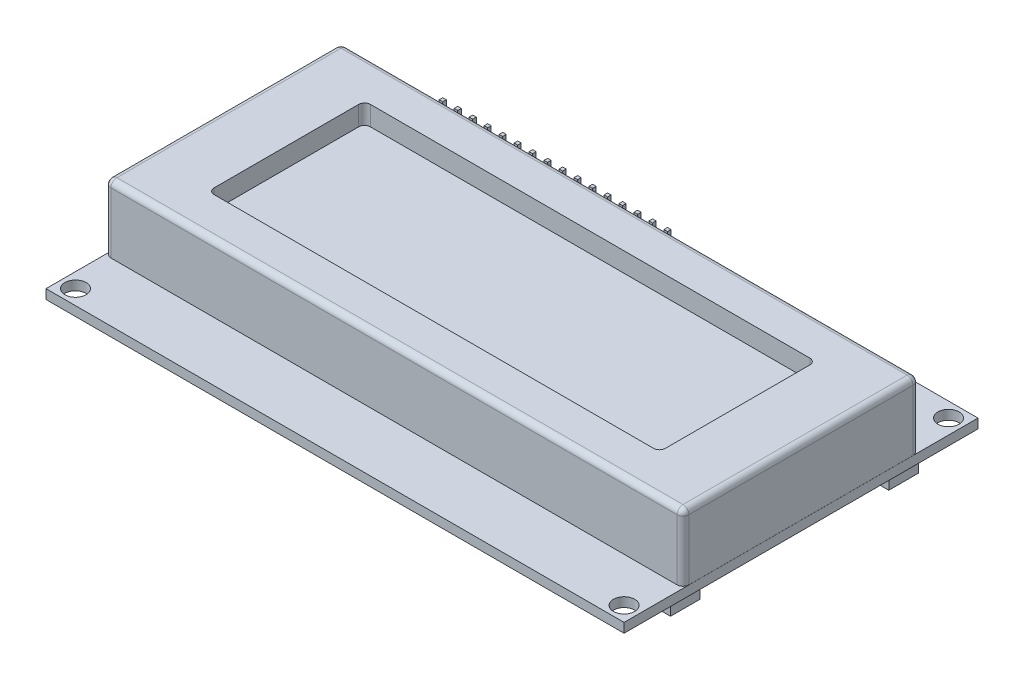
from build123d import *

# Parameters (mm, degrees)
SKETCH1_W               = 98
SKETCH1_H               = 60
BOSS_EXTRUDE1_DEPTH     = 1.6
CUT_EXTRUDE1_START      = -2.6
SKETCH2_R               = 1.8
CUT_EXTRUDE1_DEPTH      = 3.6
SKETCH5_W               = 7
SKETCH5_H               = 5
BOSS_EXTRUDE3_DEPTH     = 2.57
MIRROR2_START           = -2.6
MIRROR2_COPY_1_SKETCH_R = 1.8
MIRROR2_COPY_1_DEPTH    = 3.6
MIRROR2_COPY_2_SKETCH_W = 7
MIRROR2_COPY_2_SKETCH_H = 5
MIRROR2_COPY_2_DEPTH    = 2.57
SKETCH3_W               = 97.98
SKETCH3_H               = 40
BOSS_EXTRUDE2_DEPTH     = 11.3
SKETCH4_W               = 76.5
SKETCH4_H               = 26.5
CUT_EXTRUDE2_DEPTH      = 3.3
FILLET1_R               = 1
SKETCH6_W               = 47.2
SKETCH6_H               = 19
BOSS_EXTRUDE4_DEPTH     = 11.5
SKETCH7_W               = 0.6
SKETCH7_H               = 0.6
BOSS_EXTRUDE5_DEPTH     = 6.5
SKETCH9_W               = 0.6
SKETCH9_H               = 0.6
BOSS_EXTRUDE7_DEPTH     = 3.9
LPATTERN1_COUNT         = 16
LPATTERN1_PITCH         = 2.54


with BuildPart() as part:
    # Sketch1 → Boss-Extrude1 (new body)
    with BuildSketch(Plane(origin=(0, 0, 0), x_dir=(1, 0, 0), z_dir=(0, 1, 0))):
        Rectangle(SKETCH1_W, SKETCH1_H)
    extrude(amount=BOSS_EXTRUDE1_DEPTH)

    # Sketch2 → Cut-Extrude1 (cut)
    with BuildSketch(Plane(origin=(0, 1.6, 0), x_dir=(1, 0, 0), z_dir=(0, 1, 0)).offset(CUT_EXTRUDE1_START)):
        with Locations((-46.5, 27.5)):
            Circle(SKETCH2_R)
    cut_extrude1 = extrude(amount=CUT_EXTRUDE1_DEPTH, mode=Mode.SUBTRACT)

    # Sketch5 → Boss-Extrude3 (add)
    with BuildSketch(Plane.XZ):
        with Locations((-44.375, 18.5)):
            Rectangle(SKETCH5_W, SKETCH5_H)
        with Locations((-16, 18.5)):
            Rectangle(SKETCH5_W, SKETCH5_H)
    boss_extrude3 = extrude(amount=BOSS_EXTRUDE3_DEPTH)

    # Mirror1: Cut-Extrude1, Boss-Extrude3 across plane
    add(cut_extrude1.mirror(Plane.XY), mode=Mode.SUBTRACT)
    add(boss_extrude3.mirror(Plane.XY))

    # Mirror2: Cut-Extrude1, Boss-Extrude3 across plane
    add(cut_extrude1.mirror(Plane(origin=(0, 0, 0), x_dir=(0, 0, 1), z_dir=(1, 0, 0))), mode=Mode.SUBTRACT)
    add(boss_extrude3.mirror(Plane(origin=(0, 0, 0), x_dir=(0, 0, 1), z_dir=(1, 0, 0))))

    # Mirror2 copy 1 sketch → Mirror2 copy 1 (cut)
    with BuildSketch(Plane(origin=(0, 1.6, 0), x_dir=(-1, 0, 0), z_dir=(0, 1, 0)).offset(MIRROR2_START)):
        with Locations((-46.5, 27.5)):
            Circle(MIRROR2_COPY_1_SKETCH_R)
    extrude(amount=MIRROR2_COPY_1_DEPTH, mode=Mode.SUBTRACT)

    # Mirror2 copy 2 sketch → Mirror2 copy 2 (add)
    with BuildSketch(Plane(origin=(0, 0, 0), x_dir=(-1, 0, 0), z_dir=(0, -1, 0))):
        with Locations((-44.375, 18.5)):
            Rectangle(MIRROR2_COPY_2_SKETCH_W, MIRROR2_COPY_2_SKETCH_H)
        with Locations((-16, 18.5)):
            Rectangle(MIRROR2_COPY_2_SKETCH_W, MIRROR2_COPY_2_SKETCH_H)
    extrude(amount=MIRROR2_COPY_2_DEPTH)

    # Sketch3 → Boss-Extrude2 (add)
    with BuildSketch(Plane(origin=(0, 1.6, 0), x_dir=(1, 0, 0), z_dir=(0, 1, 0))):
        Rectangle(SKETCH3_W, SKETCH3_H)
    extrude(amount=BOSS_EXTRUDE2_DEPTH)

    # Sketch4 → Cut-Extrude2 (cut)
    with BuildSketch(Plane(origin=(0, 12.9, 0), x_dir=(1, 0, 0), z_dir=(0, 1, 0))):
        Rectangle(SKETCH4_W, SKETCH4_H)
    extrude(amount=-CUT_EXTRUDE2_DEPTH, mode=Mode.SUBTRACT)

    # Fillet1
    fillet1_edges = [part.edges().sort_by_distance(p)[0] for p in [
        (48.99, 7.25, 20),
        (48.99, 7.25, -20),
        (-48.99, 7.25, -20),
        (-48.99, 7.25, 20),
        (48.99, 12.9, 0),
        (0, 12.9, -20),
        (-48.99, 12.9, 0),
        (0, 12.9, 20),
        (38.25, 11.25, -13.25),
        (38.25, 11.25, 13.25),
        (-38.25, 11.25, 13.25),
        (-38.25, 11.25, -13.25),
    ]]
    fillet(fillet1_edges, radius=FILLET1_R)

    # Sketch6 → Boss-Extrude4 (add)
    with BuildSketch(Plane.XZ):
        with Locations((-17.2, -19.5)):
            Rectangle(SKETCH6_W, SKETCH6_H)
    extrude(amount=BOSS_EXTRUDE4_DEPTH)

    # Sketch7 → Boss-Extrude5 (add)
    with BuildSketch(Plane(origin=(-40.8, 0, 0), x_dir=(0, 0, -1), z_dir=(1, 0, 0))):
        with Locations((15.25, -8.8)):
            Rectangle(SKETCH7_W, SKETCH7_H)
        with Locations((17.79, -8.8)):
            Rectangle(SKETCH7_W, SKETCH7_H)
        with Locations((20.33, -8.8)):
            Rectangle(SKETCH7_W, SKETCH7_H)
        with Locations((22.87, -8.8)):
            Rectangle(SKETCH7_W, SKETCH7_H)
    extrude(amount=-BOSS_EXTRUDE5_DEPTH)

    # Sketch9 → Boss-Extrude7 (add)
    with BuildSketch(Plane(origin=(0, 1.6, 0), x_dir=(1, 0, 0), z_dir=(0, 1, 0))):
        with Locations((-39.2, 27.46)):
            Rectangle(SKETCH9_W, SKETCH9_H)
    boss_extrude7 = extrude(amount=BOSS_EXTRUDE7_DEPTH)

    # LPattern1: Boss-Extrude7 ×16
    with Locations(*[(i * LPATTERN1_PITCH, 0, 0) for i in range(1, LPATTERN1_COUNT)]):
        add(boss_extrude7)


solid = part.part
